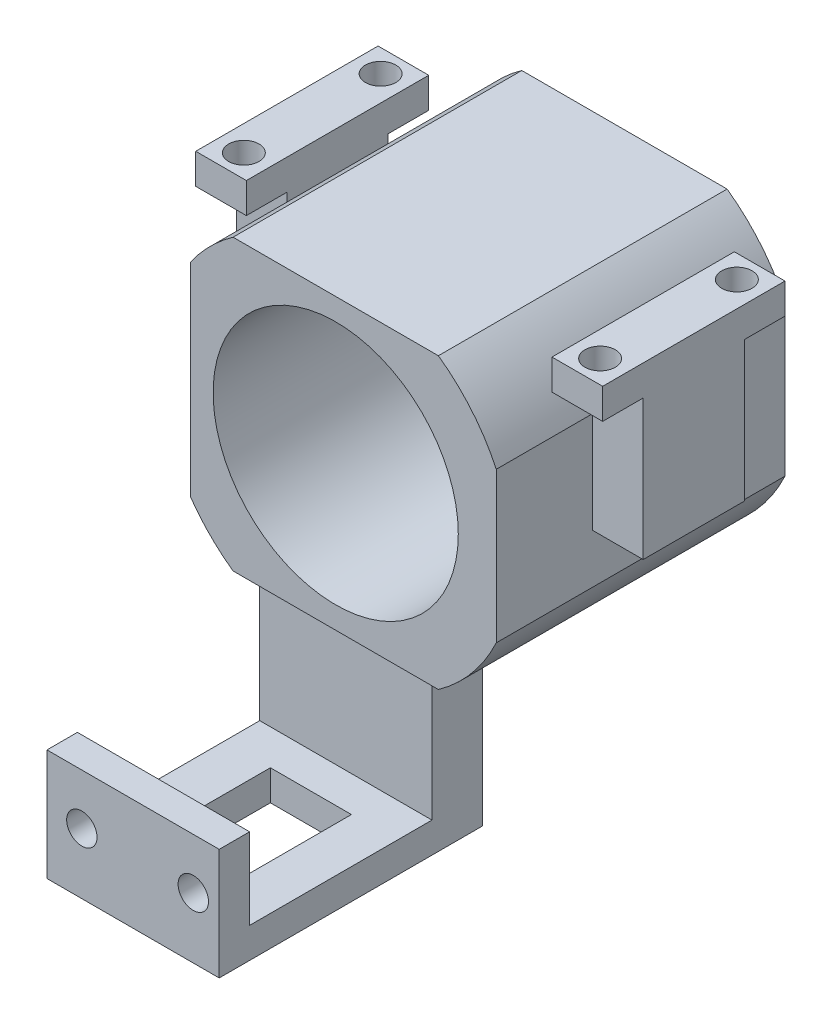
from build123d import *

# Parameters (mm, degrees)
SKETCH1_R               = 12.1
BOSS_EXTRUDE1_DEPTH     = 3.5
SKETCH1_4_R             = 12.1
BOSS_EXTRUDE2_DEPTH     = 28.5
CUT_EXTRUDE1_DEPTH      = 36.595224044
CUT_EXTRUDE1_DEPTH_BACK = 36.595224044
SKETCH3_W               = 4.5
SKETCH3_H               = 2.297717899
SKETCH6_W               = 17
SKETCH6_H               = 5
BOSS_EXTRUDE4_DEPTH     = 15.48
SKETCH7_W               = 17
SKETCH7_H               = 3
BOSS_EXTRUDE5_DEPTH     = 21
SKETCH10_W              = 8
SKETCH10_H              = 15
CUT_EXTRUDE4_DEPTH      = 5
SKETCH12_W              = 17
SKETCH12_H              = 3
BOSS_EXTRUDE8_DEPTH     = 8
SKETCH9_R               = 1.5
CUT_EXTRUDE5_DEPTH      = 4
SKETCH13_W              = 10
SKETCH13_H              = 4
BOSS_EXTRUDE9_DEPTH     = 5
SKETCH15_W              = 5
SKETCH15_H              = 10
BOSS_EXTRUDE10_DEPTH    = 11.96
SKETCH17_W              = 5
SKETCH17_H              = 3
BOSS_EXTRUDE11_DEPTH    = 4
SKETCH16_W              = 5
SKETCH16_H              = 3
BOSS_EXTRUDE12_DEPTH    = 4
SKETCH20_W              = 10
SKETCH20_H              = 4
BOSS_EXTRUDE13_DEPTH    = 5
SKETCH22_W              = 5
SKETCH22_H              = 10
BOSS_EXTRUDE14_DEPTH    = 12.81
SKETCH26_W              = 5
SKETCH26_H              = 3
BOSS_EXTRUDE15_DEPTH    = 4
SKETCH25_W              = 5
SKETCH25_H              = 3
BOSS_EXTRUDE16_DEPTH    = 4
CUT_EXTRUDE7_DEPTH      = 69.729605581
CUT_EXTRUDE7_DEPTH_BACK = 69.729605581
SKETCH27_R              = 1.5
CUT_EXTRUDE8_DEPTH      = 69.733657013
CUT_EXTRUDE8_DEPTH_BACK = 69.733657013
SKETCH28_R              = 1.5


with BuildPart() as part:
    # Sketch1 → Boss-Extrude1 (new body)
    with BuildSketch(Plane.XY):
        Circle(SKETCH1_R)
    extrude(amount=BOSS_EXTRUDE1_DEPTH)

    # Sketch1_4 → Boss-Extrude2 (add)
    with BuildSketch(Plane.XY):
        with BuildLine():
            Line((10.134542374, 14.266781377), (-10.134542374, 14.266781377))
            ThreePointArc((-10.134542374, 14.266781377), (-12.405882938, 12.342773939), (-14.318281607, 10.061650551))
            Line((-14.318281607, 10.061650551), (-14.318281607, -10.061650551))
            ThreePointArc((-14.318281607, -10.061650551), (-12.406080895, -12.342574968), (-10.135, -14.266456287))
            Line((-10.135, -14.266456287), (10.135, -14.266456287))
            ThreePointArc((10.135, -14.266456287), (13.436306455, -11.212299891), (15.850202646, -7.417619301))
            Line((15.850202646, -7.417619301), (15.850202646, 7.417619301))
            ThreePointArc((15.850202646, 7.417619301), (13.436126626, 11.212515386), (10.134542374, 14.266781377))
        make_face()
        Circle(SKETCH1_4_R, mode=Mode.SUBTRACT)
    extrude(amount=BOSS_EXTRUDE2_DEPTH)

    # Sketch3 → Cut-Extrude1 (cut, two sides: drawn at the far end of the back side and taken through both)
    with BuildSketch(Plane(origin=(0, 0, 0), x_dir=(-1, 0, 0), z_dir=(0, 0, -1)).offset(-CUT_EXTRUDE1_DEPTH_BACK)):
        with Locations((-0.45, 9.367922428)):
            Rectangle(SKETCH3_W, SKETCH3_H)
        with Locations((-0.45, -9.367922428)):
            Rectangle(SKETCH3_W, SKETCH3_H)
    extrude(amount=CUT_EXTRUDE1_DEPTH + CUT_EXTRUDE1_DEPTH_BACK, mode=Mode.SUBTRACT)

    # Sketch6 → Boss-Extrude4 (add)
    with BuildSketch(Plane(origin=(0, -14.266456287, 0), x_dir=(-1, 0, 0), z_dir=(0, -1, 0))):
        with Locations((0, -25)):
            Rectangle(SKETCH6_W, SKETCH6_H)
    extrude(amount=BOSS_EXTRUDE4_DEPTH)

    # Sketch7 → Boss-Extrude5 (add)
    with BuildSketch(Plane.XY.offset(27.5)):
        with Locations((0, -28.246456287)):
            Rectangle(SKETCH7_W, SKETCH7_H)
    extrude(amount=BOSS_EXTRUDE5_DEPTH)

    # Sketch10 → Cut-Extrude4 (cut, symmetric)
    with BuildSketch(Plane(origin=(0, -29.746456287, 0), x_dir=(-1, 0, 0), z_dir=(0, -1, 0))):
        with Locations((-0.050406815, -38.5)):
            Rectangle(SKETCH10_W, SKETCH10_H)
    extrude(amount=CUT_EXTRUDE4_DEPTH, both=True, mode=Mode.SUBTRACT)

    # Sketch12 → Boss-Extrude8 (add)
    with BuildSketch(Plane(origin=(0, -26.746456287, 0), x_dir=(1, 0, 0), z_dir=(0, 1, 0))):
        with Locations((0, -47)):
            Rectangle(SKETCH12_W, SKETCH12_H)
    extrude(amount=BOSS_EXTRUDE8_DEPTH)

    # Sketch9 → Cut-Extrude5 (cut, symmetric)
    with BuildSketch(Plane.XY.offset(48.5)):
        with Locations((-5.060010985, -23.75132246)):
            Circle(SKETCH9_R)
        with Locations((5.939989015, -23.75132246)):
            Circle(SKETCH9_R)
    extrude(amount=CUT_EXTRUDE5_DEPTH, both=True, mode=Mode.SUBTRACT)

    # Sketch13 → Boss-Extrude9 (add)
    with BuildSketch(Plane.ZY.offset(14.318281607)):
        with Locations((14, 0.308707646)):
            Rectangle(SKETCH13_W, SKETCH13_H)
    extrude(amount=BOSS_EXTRUDE9_DEPTH)

    # Sketch15 → Boss-Extrude10 (add)
    with BuildSketch(Plane(origin=(0, 2.308707646, 0), x_dir=(1, 0, 0), z_dir=(0, 1, 0))):
        with Locations((-16.818281607, -14)):
            Rectangle(SKETCH15_W, SKETCH15_H)
    extrude(amount=BOSS_EXTRUDE10_DEPTH)

    # Sketch17 → Boss-Extrude11 (add)
    with BuildSketch(Plane.XY.offset(19)):
        with Locations((-16.818281607, 12.768707646)):
            Rectangle(SKETCH17_W, SKETCH17_H)
    extrude(amount=BOSS_EXTRUDE11_DEPTH)

    # Sketch16 → Boss-Extrude12 (add)
    with BuildSketch(Plane(origin=(0, 0, 9), x_dir=(-1, 0, 0), z_dir=(0, 0, -1))):
        with Locations((16.818281607, 12.768707646)):
            Rectangle(SKETCH16_W, SKETCH16_H)
    extrude(amount=BOSS_EXTRUDE12_DEPTH)

    # Sketch20 → Boss-Extrude13 (add)
    with BuildSketch(Plane(origin=(15.850202646, 0, 0), x_dir=(0, 0, -1), z_dir=(1, 0, 0))):
        with Locations((-14, -0.547619301)):
            Rectangle(SKETCH20_W, SKETCH20_H)
    extrude(amount=BOSS_EXTRUDE13_DEPTH)

    # Sketch22 → Boss-Extrude14 (add)
    with BuildSketch(Plane(origin=(0, 1.452380699, 0), x_dir=(1, 0, 0), z_dir=(0, 1, 0))):
        with Locations((18.350202646, -14)):
            Rectangle(SKETCH22_W, SKETCH22_H)
    extrude(amount=BOSS_EXTRUDE14_DEPTH)

    # Sketch26 → Boss-Extrude15 (add)
    with BuildSketch(Plane.XY.offset(19)):
        with Locations((18.350202646, 12.762380699)):
            Rectangle(SKETCH26_W, SKETCH26_H)
    extrude(amount=BOSS_EXTRUDE15_DEPTH)

    # Sketch25 → Boss-Extrude16 (add)
    with BuildSketch(Plane(origin=(0, 0, 9), x_dir=(-1, 0, 0), z_dir=(0, 0, -1))):
        with Locations((-18.350202646, 12.762380699)):
            Rectangle(SKETCH25_W, SKETCH25_H)
    extrude(amount=BOSS_EXTRUDE16_DEPTH)

    # Sketch27 → Cut-Extrude7 (cut, two sides: drawn at the far end of the back side and taken through both)
    with BuildSketch(Plane(origin=(0, 14.262380699, 0), x_dir=(1, 0, 0), z_dir=(0, 1, 0)).offset(-CUT_EXTRUDE7_DEPTH_BACK)):
        with Locations((18.350202646, -20.75)):
            Circle(SKETCH27_R)
        with Locations((18.350202646, -7.25)):
            Circle(SKETCH27_R)
    extrude(amount=CUT_EXTRUDE7_DEPTH + CUT_EXTRUDE7_DEPTH_BACK, mode=Mode.SUBTRACT)

    # Sketch28 → Cut-Extrude8 (cut, two sides: drawn at the far end of the back side and taken through both)
    with BuildSketch(Plane(origin=(0, 14.268707646, 0), x_dir=(1, 0, 0), z_dir=(0, 1, 0)).offset(-CUT_EXTRUDE8_DEPTH_BACK)):
        with Locations((-16.818281607, -7.25)):
            Circle(SKETCH28_R)
        with Locations((-16.818281607, -20.75)):
            Circle(SKETCH28_R)
    extrude(amount=CUT_EXTRUDE8_DEPTH + CUT_EXTRUDE8_DEPTH_BACK, mode=Mode.SUBTRACT)


solid = part.part
